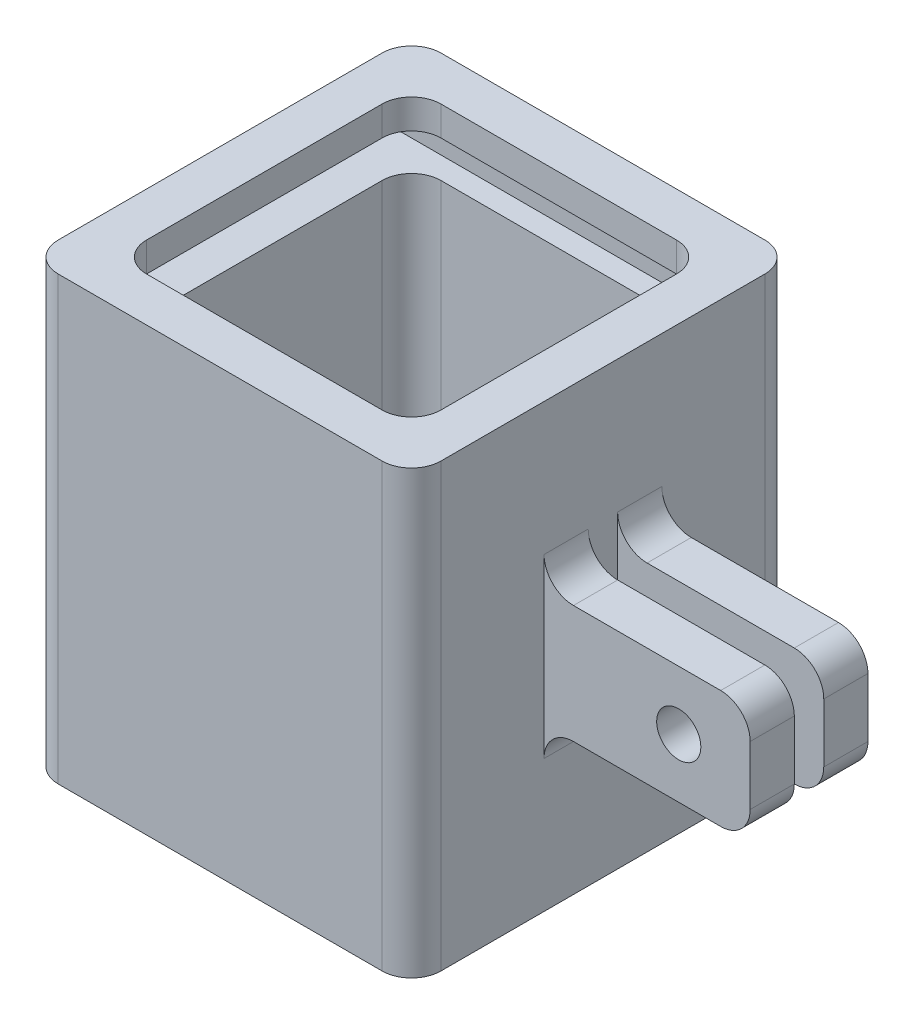
from build123d import *

# Parameters (mm, degrees)
SKETCH1_W               = 26
SKETCH1_H               = 26
SKETCH1_W_2             = 20
SKETCH1_H_2             = 20
BOSS_EXTRUDE1_DEPTH     = 30
SKETCH2_W               = 20
SKETCH2_H               = 20
BOSS_EXTRUDE2_DEPTH     = 5
FILLET1_R               = 2
SKETCH6_W               = 3
SKETCH6_H               = 8
BOSS_EXTRUDE4_DEPTH     = 14
FILLET2_R               = 2
FILLET3_R               = 2
SKETCH7_R               = 1.5
CUT_EXTRUDE2_DEPTH      = 10
CUT_EXTRUDE2_DEPTH_BACK = 18
SKETCH9_W               = 23
SKETCH9_H               = 2.5
CUT_EXTRUDE3_DEPTH      = 23
FILLET4_R               = 2


with BuildPart() as part:
    # Sketch1 → Boss-Extrude1 (new body)
    with BuildSketch(Plane(origin=(0, 0, 0), x_dir=(1, 0, 0), z_dir=(0, 1, 0))):
        Rectangle(SKETCH1_W, SKETCH1_H)
        Rectangle(SKETCH1_W_2, SKETCH1_H_2, mode=Mode.SUBTRACT)
    extrude(amount=BOSS_EXTRUDE1_DEPTH)

    # Sketch2 → Boss-Extrude2 (add)
    with BuildSketch(Plane.XZ):
        Rectangle(SKETCH2_W, SKETCH2_H)
    extrude(amount=-BOSS_EXTRUDE2_DEPTH)

    # Fillet1
    fillet1_edges = [part.edges().sort_by_distance(p)[0] for p in [
        (-10, 17.5, -10),
        (-10, 17.5, 10),
        (10, 17.5, 10),
        (10, 17.5, -10),
        (-13, 15, -13),
        (13, 15, -13),
        (13, 15, 13),
        (-13, 15, 13),
    ]]
    fillet(fillet1_edges, radius=FILLET1_R)

    # Sketch6 → Boss-Extrude4 (add)
    with BuildSketch(Plane(origin=(13, 0, 0), x_dir=(0, 0, -1), z_dir=(1, 0, 0))):
        with Locations((-2.5, 15)):
            Rectangle(SKETCH6_W, SKETCH6_H)
        with Locations((2.5, 15)):
            Rectangle(SKETCH6_W, SKETCH6_H)
    extrude(amount=BOSS_EXTRUDE4_DEPTH)

    # Fillet2
    fillet2_edges = [part.edges().sort_by_distance(p)[0] for p in [
        (13, 11, 2.5),
        (13, 19, 2.5),
        (13, 19, -2.5),
        (13, 11, -2.5),
    ]]
    fillet(fillet2_edges, radius=FILLET2_R)

    # Fillet3
    fillet3_edges = [part.edges().sort_by_distance(p)[0] for p in [
        (27, 11, 2.5),
        (27, 19, 2.5),
        (27, 19, -2.5),
        (27, 11, -2.5),
    ]]
    fillet(fillet3_edges, radius=FILLET3_R)

    # Sketch7 → Cut-Extrude2 (cut, two sides)
    with BuildSketch(Plane(origin=(0, 0, -4), x_dir=(-1, 0, 0), z_dir=(0, 0, -1))) as cut_extrude2_sk:
        with Locations((-22.15, 15)):
            Circle(SKETCH7_R)
    extrude(amount=CUT_EXTRUDE2_DEPTH, mode=Mode.SUBTRACT)
    extrude(cut_extrude2_sk.sketch, amount=-CUT_EXTRUDE2_DEPTH_BACK, mode=Mode.SUBTRACT)

    # Sketch9 → Cut-Extrude3 (cut)
    with BuildSketch(Plane.ZY.offset(13)):
        with Locations((0, 26.75)):
            Rectangle(SKETCH9_W, SKETCH9_H)
    extrude(amount=-CUT_EXTRUDE3_DEPTH, mode=Mode.SUBTRACT)

    # Fillet4
    fillet4_edges = [part.edges().sort_by_distance(p)[0] for p in [
        (10, 26.75, 11.5),
        (10, 26.75, -11.5),
    ]]
    fillet(fillet4_edges, radius=FILLET4_R)


solid = part.part
